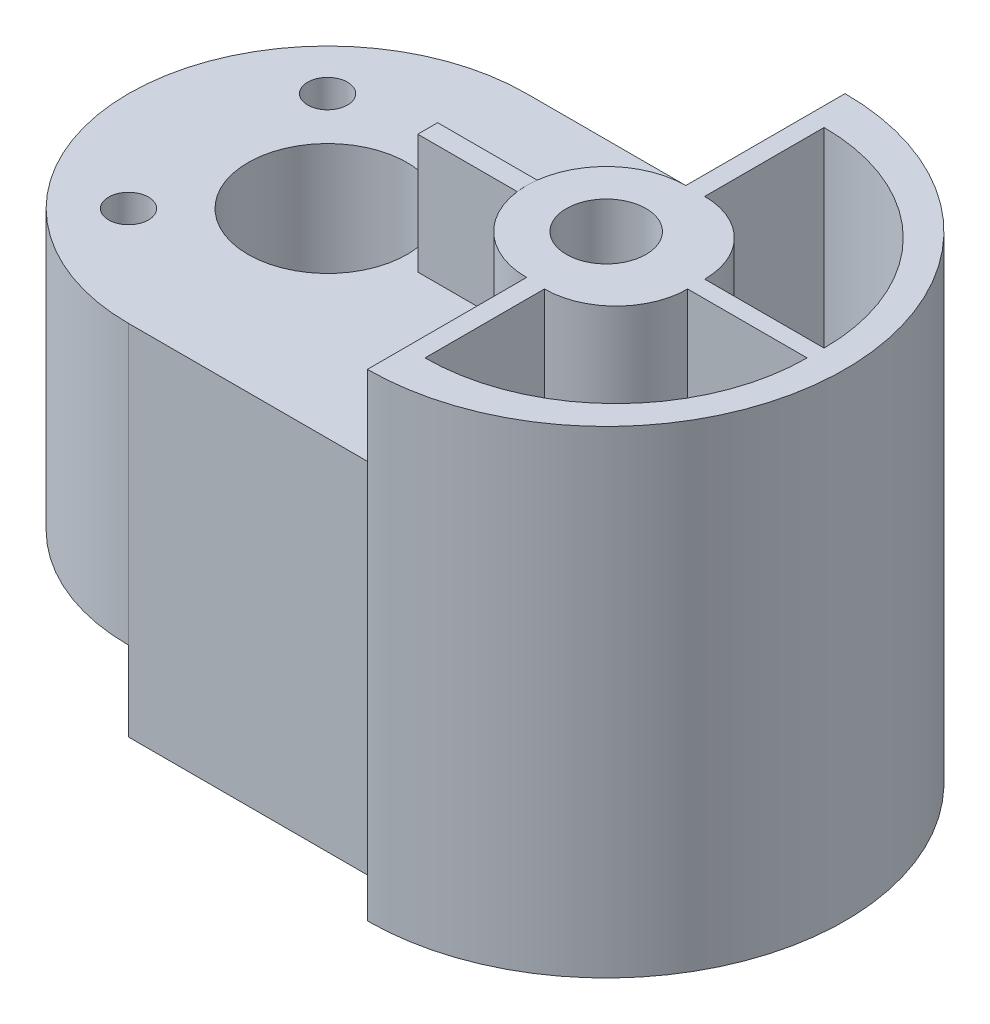
from build123d import *

# Parameters (mm, degrees)
SKETCH1_W           = 180
SKETCH1_H           = 120
BOSS_EXTRUDE2_DEPTH = 120
SKETCH2_W           = 110
SKETCH2_H           = 10
CUT_EXTRUDE1_DEPTH  = 120
CUT_EXTRUDE2_DEPTH  = 120
CUT_EXTRUDE3_DEPTH  = 120
CUT_EXTRUDE4_DEPTH  = 120
SKETCH6_R           = 5
CUT_EXTRUDE5_DEPTH  = 120
SKETCH7_R           = 10
CUT_EXTRUDE6_DEPTH  = 120
CUT_EXTRUDE7_DEPTH  = 30
BOSS_EXTRUDE3_DEPTH = 30
CUT_EXTRUDE8_DEPTH  = 60
CUT_EXTRUDE9_DEPTH  = 60
CUT_EXTRUDE10_DEPTH = 60
CUT_EXTRUDE11_DEPTH = 60
SKETCH15_W          = 25
SKETCH15_H          = 5
BOSS_EXTRUDE5_DEPTH = 29.999
SKETCH16_R          = 10
CUT_EXTRUDE12_DEPTH = 125.999
SKETCH17_R          = 20
SKETCH17_R_2        = 10
CUT_EXTRUDE13_DEPTH = 30
SKETCH19_R          = 10
SKETCH19_R_2        = 5
CUT_EXTRUDE14_DEPTH = 20
SKETCH20_R          = 20
SKETCH20_R_2        = 10
CUT_EXTRUDE15_DEPTH = 84.461973219
BOSS_EXTRUDE6_DEPTH = 20
BOSS_EXTRUDE7_DEPTH = 20


with BuildPart() as part:
    # Sketch1 → Boss-Extrude2 (new body)
    with BuildSketch(Plane(origin=(0, 0, 0), x_dir=(1, 0, 0), z_dir=(0, 1, 0))):
        with Locations((90, 60)):
            Rectangle(SKETCH1_W, SKETCH1_H)
    extrude(amount=BOSS_EXTRUDE2_DEPTH)

    # Sketch2 → Cut-Extrude1 (cut)
    with BuildSketch(Plane(origin=(0, 0, 0), x_dir=(1, 0, 0), z_dir=(0, 1, 0))):
        with Locations((55, 115)):
            Rectangle(SKETCH2_W, SKETCH2_H)
        with Locations((55, 5)):
            Rectangle(SKETCH2_W, SKETCH2_H)
    extrude(amount=CUT_EXTRUDE1_DEPTH, mode=Mode.SUBTRACT)

    # Sketch3 → Cut-Extrude2 (cut)
    with BuildSketch(Plane(origin=(0, 120, 0), x_dir=(1, 0, 0), z_dir=(0, 1, 0))):
        with BuildLine():
            Line((110, 110), (110, 120))
            Line((110, 120), (120, 120))
            ThreePointArc((120, 120), (117.071067812, 112.928932188), (110, 110))
        make_face()
        with BuildLine():
            Line((120, 0), (110, 0))
            Line((110, 0), (110, 10))
            ThreePointArc((110, 10), (117.071067812, 7.071067812), (120, 0))
        make_face()
    extrude(amount=-CUT_EXTRUDE2_DEPTH, mode=Mode.SUBTRACT)

    # Sketch4 → Cut-Extrude3 (cut)
    with BuildSketch(Plane(origin=(0, 120, 0), x_dir=(1, 0, 0), z_dir=(0, 1, 0))):
        with BuildLine():
            Line((180, 120), (120, 120))
            ThreePointArc((120, 120), (162.426406871, 102.426406871), (180, 60))
            Line((180, 60), (180, 120))
        make_face()
        with BuildLine():
            Line((180, 0), (180, 60))
            ThreePointArc((180, 60), (162.426406871, 17.573593129), (120, 0))
            Line((120, 0), (180, 0))
        make_face()
    extrude(amount=-CUT_EXTRUDE3_DEPTH, mode=Mode.SUBTRACT)

    # Sketch5 → Cut-Extrude4 (cut)
    with BuildSketch(Plane(origin=(0, 120, 0), x_dir=(1, 0, 0), z_dir=(0, 1, 0))):
        with BuildLine():
            ThreePointArc((0, 59.999999737), (14.644660848, 95.355338966), (50, 110))
            Line((50, 110), (0, 110))
            Line((0, 110), (0, 59.999999737))
        make_face()
        with BuildLine():
            ThreePointArc((50, 10), (14.644661034, 24.644660848), (0, 59.999999737))
            Line((0, 59.999999737), (0, 10))
            Line((0, 10), (50, 10))
        make_face()
    extrude(amount=-CUT_EXTRUDE4_DEPTH, mode=Mode.SUBTRACT)

    # Sketch6 → Cut-Extrude5 (cut)
    with BuildSketch(Plane(origin=(0, 120, 0), x_dir=(1, 0, 0), z_dir=(0, 1, 0))):
        with Locations((25, 85)):
            Circle(SKETCH6_R)
        with Locations((25, 35)):
            Circle(SKETCH6_R)
    extrude(amount=-CUT_EXTRUDE5_DEPTH, mode=Mode.SUBTRACT)

    # Sketch7 → Cut-Extrude6 (cut)
    with BuildSketch(Plane(origin=(0, 120, 0), x_dir=(1, 0, 0), z_dir=(0, 1, 0))):
        with Locations((120, 60)):
            Circle(SKETCH7_R)
    extrude(amount=-CUT_EXTRUDE6_DEPTH, mode=Mode.SUBTRACT)

    # Sketch9 → Cut-Extrude7 (cut)
    with BuildSketch(Plane(origin=(0, 120, 0), x_dir=(1, 0, 0), z_dir=(0, 1, 0))):
        with BuildLine():
            Line((120, 120), (120, 0))
            ThreePointArc((120, 0), (117.071067812, 7.071067812), (110, 10))
            Line((110, 10), (50, 10))
            ThreePointArc((50, 10), (0, 60), (50, 110))
            Line((50, 110), (110, 110))
            ThreePointArc((110, 110), (117.071067812, 112.928932188), (120, 120))
        make_face()
    extrude(amount=-CUT_EXTRUDE7_DEPTH, mode=Mode.SUBTRACT)

    # Sketch10 → Boss-Extrude3 (add)
    with BuildSketch(Plane(origin=(0, 90, 0), x_dir=(1, 0, 0), z_dir=(0, 1, 0))):
        with BuildLine():
            Line((120, 70), (120, 80))
            ThreePointArc((120, 80), (100, 60), (120, 40))
            Line((120, 40), (120, 50))
            ThreePointArc((120, 50), (110, 60), (120, 70))
        make_face()
    extrude(amount=BOSS_EXTRUDE3_DEPTH)

    # Sketch11 → Cut-Extrude8 (cut)
    with BuildSketch(Plane(origin=(0, 120, 0), x_dir=(1, 0, 0), z_dir=(0, 1, 0))):
        with BuildLine():
            Line((124.743133772, 80), (124.743133772, 110))
            ThreePointArc((124.743133772, 110), (158.684259269, 95.941125497), (172.743133772, 62))
            Line((172.743133772, 62), (142.743133772, 62))
            ThreePointArc((142.743133772, 62), (137.471055833, 74.727922061), (124.743133772, 80))
        make_face()
    extrude(amount=-CUT_EXTRUDE8_DEPTH, mode=Mode.SUBTRACT)

    # Sketch12 → Cut-Extrude9 (cut)
    with BuildSketch(Plane(origin=(0, 120, 0), x_dir=(1, 0, 0), z_dir=(0, 1, 0))):
        with BuildLine():
            Line((124.743133772, 39.722678499), (124.743133772, 9.722678499))
            ThreePointArc((124.743133772, 9.722678499), (158.684259269, 23.781553002), (172.743133772, 57.722678499))
            Line((172.743133772, 57.722678499), (142.743133772, 57.722678499))
            ThreePointArc((142.743133772, 57.722678499), (137.471055833, 44.994756437), (124.743133772, 39.722678499))
        make_face()
    extrude(amount=-CUT_EXTRUDE9_DEPTH, mode=Mode.SUBTRACT)

    # Sketch13 → Cut-Extrude10 (cut)
    with BuildSketch(Plane(origin=(0, 60, 0), x_dir=(1, 0, 0), z_dir=(0, 1, 0))):
        with BuildLine():
            Line((124.743133772, 80), (124.743133772, 100))
            ThreePointArc((124.743133772, 100), (151.613191457, 88.870057685), (162.743133772, 62))
            Line((162.743133772, 62), (142.743133772, 62))
            ThreePointArc((142.743133772, 62), (137.471055833, 74.727922061), (124.743133772, 80))
        make_face()
    extrude(amount=-CUT_EXTRUDE10_DEPTH, mode=Mode.SUBTRACT)

    # Sketch14 → Cut-Extrude11 (cut)
    with BuildSketch(Plane(origin=(0, 60, 0), x_dir=(1, 0, 0), z_dir=(0, 1, 0))):
        with BuildLine():
            Line((124.743133772, 39.722678499), (124.743133772, 19.722678499))
            ThreePointArc((124.743133772, 19.722678499), (151.613191457, 30.852620814), (162.743133772, 57.722678499))
            Line((162.743133772, 57.722678499), (142.743133772, 57.722678499))
            ThreePointArc((142.743133772, 57.722678499), (137.471055833, 44.994756437), (124.743133772, 39.722678499))
        make_face()
    extrude(amount=-CUT_EXTRUDE11_DEPTH, mode=Mode.SUBTRACT)

    # Sketch15 → Boss-Extrude5 (add)
    with BuildSketch(Plane(origin=(0, 90, 0), x_dir=(1, 0, 0), z_dir=(0, 1, 0))):
        with Locations((87.656865167, 60)):
            Rectangle(SKETCH15_W, SKETCH15_H)
    extrude(amount=BOSS_EXTRUDE5_DEPTH)

    # Sketch16 → Cut-Extrude12 (cut)
    with BuildSketch(Plane(origin=(0, 90, 0), x_dir=(1, 0, 0), z_dir=(0, 1, 0))):
        with Locations((50, 60)):
            Circle(SKETCH16_R)
    extrude(amount=-CUT_EXTRUDE12_DEPTH, mode=Mode.SUBTRACT)

    # Sketch17 → Cut-Extrude13 (cut)
    with BuildSketch(Plane(origin=(0, 90, 0), x_dir=(1, 0, 0), z_dir=(0, 1, 0))):
        with Locations((50, 60)):
            Circle(SKETCH17_R)
        with Locations((50, 60)):
            Circle(SKETCH17_R_2, mode=Mode.SUBTRACT)
    extrude(amount=-CUT_EXTRUDE13_DEPTH, mode=Mode.SUBTRACT)

    # Sketch19 → Cut-Extrude14 (cut)
    with BuildSketch(Plane(origin=(0, 0, 0), x_dir=(-1, 0, 0), z_dir=(0, -1, 0))):
        with Locations((-50, 60)):
            Circle(SKETCH19_R)
        with BuildLine():
            Line((-50, 110), (-50, 10))
            ThreePointArc((-50, 10), (0, 60), (-50, 110))
        make_face()
        with Locations((-25, 35)):
            Circle(SKETCH19_R_2, mode=Mode.SUBTRACT)
        with Locations((-25, 85)):
            Circle(SKETCH19_R_2, mode=Mode.SUBTRACT)
    extrude(amount=-CUT_EXTRUDE14_DEPTH, mode=Mode.SUBTRACT)

    # Sketch20 → Cut-Extrude15 (cut)
    with BuildSketch(Plane(origin=(0, 60, 0), x_dir=(1, 0, 0), z_dir=(0, 1, 0))):
        with Locations((50, 60)):
            Circle(SKETCH20_R)
        with Locations((50, 60)):
            Circle(SKETCH20_R_2, mode=Mode.SUBTRACT)
    extrude(amount=-CUT_EXTRUDE15_DEPTH, mode=Mode.SUBTRACT)

    # Sketch21 → Boss-Extrude6 (add)
    with BuildSketch(Plane.XZ.offset(-20)):
        with BuildLine():
            Line((50, -70), (50, -80))
            ThreePointArc((50, -80), (30, -60), (50, -40))
            Line((50, -40), (50, -50))
            ThreePointArc((50, -50), (40, -60), (50, -70))
        make_face()
    extrude(amount=-BOSS_EXTRUDE6_DEPTH)

    # Sketch22 → Boss-Extrude7 (add)
    with BuildSketch(Plane.XZ.offset(-20)):
        with BuildLine():
            Line((50, -70), (50, -80))
            ThreePointArc((50, -80), (70, -60), (50, -40))
            Line((50, -40), (50, -50))
            ThreePointArc((50, -50), (60, -60), (50, -70))
        make_face()
    extrude(amount=-BOSS_EXTRUDE7_DEPTH)


solid = part.part
